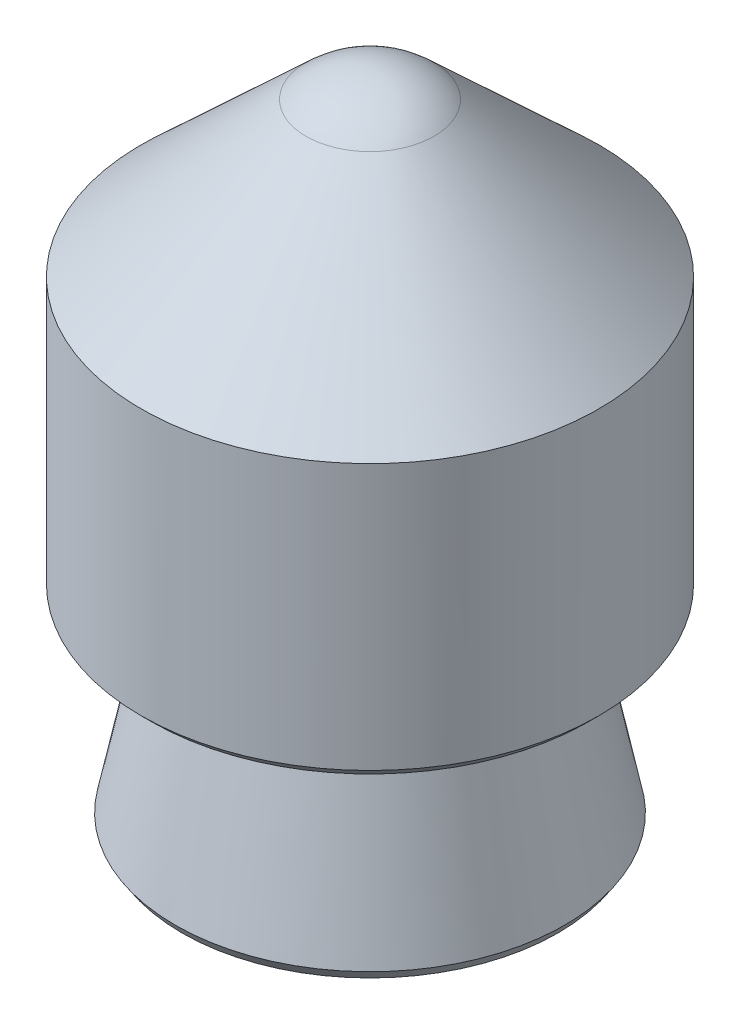
from build123d import *

# Parameters (mm, degrees)
CHAMFER1_SIZE              = 0.254
CHAMFER1_EDGE_2_SIZE2      = 0.215388858
CHAMFER1_EDGE_2_SIZE       = 0.254
SKETCH4_R                  = 3.5
CUT_EXTRUDE1_DEPTH         = 2.5
M7X0_75_TAPPED_HOLE1_D     = 6
M7X0_75_TAPPED_HOLE1_DEPTH = 10.954004
M7X0_75_TAPPED_HOLE1_TIP   = 1.802581857


with BuildPart() as part:
    # Sketch1 → Revolve1 (revolve)
    with BuildSketch(Plane.XY):
        with BuildLine():
            Line((0, 25.4), (-4.80695, 25.4))
            Line((-4.80695, 25.4), (-3.8227, 30.2387))
            Line((-3.8227, 30.2387), (-5.588, 30.2387))
            Line((-5.588, 30.2387), (-5.588, 36.9824))
            Line((-5.588, 36.9824), (-1.563367534, 40.735379295))
            ThreePointArc((-1.563367534, 40.735379295), (-0.840141831, 41.19169557), (0, 41.3512))
            Line((0, 41.3512), (0, 25.4))
        make_face()
    revolve(axis=Axis((0, 25.4, 0), (0, 1, 0)))

    # Chamfer1
    chamfer1_edges = [part.edges().sort_by_distance(p)[0] for p in [
        (5.588, 30.2387, 0),
    ]]
    chamfer(chamfer1_edges, length=CHAMFER1_SIZE)

    # Chamfer1 edge 2
    chamfer1_edge_2_edges = [part.edges().sort_by_distance(p)[0] for p in [
        (4.80695, 25.4, 0),
    ]]
    chamfer(chamfer1_edge_2_edges, length=CHAMFER1_EDGE_2_SIZE, length2=CHAMFER1_EDGE_2_SIZE2)

    # Sketch4 → Cut-Extrude1 (cut)
    with BuildSketch(Plane.XZ.offset(-25.4)):
        Circle(SKETCH4_R)
    extrude(amount=-CUT_EXTRUDE1_DEPTH, mode=Mode.SUBTRACT)

    # M7x0.75 Tapped Hole1
    with Locations(Plane(origin=(0, 25.4, 0), x_dir=(-1, 0, 0), z_dir=(0, -1, 0))):
        with Locations((0, 0), (96.139395676, -180.684699687)):
            Hole(M7X0_75_TAPPED_HOLE1_D / 2, depth=M7X0_75_TAPPED_HOLE1_DEPTH)
            with Locations((0, 0, -(M7X0_75_TAPPED_HOLE1_DEPTH + M7X0_75_TAPPED_HOLE1_TIP / 2))):  # 118° drill point
                Cone(0, M7X0_75_TAPPED_HOLE1_D / 2, M7X0_75_TAPPED_HOLE1_TIP, mode=Mode.SUBTRACT)


solid = part.part
